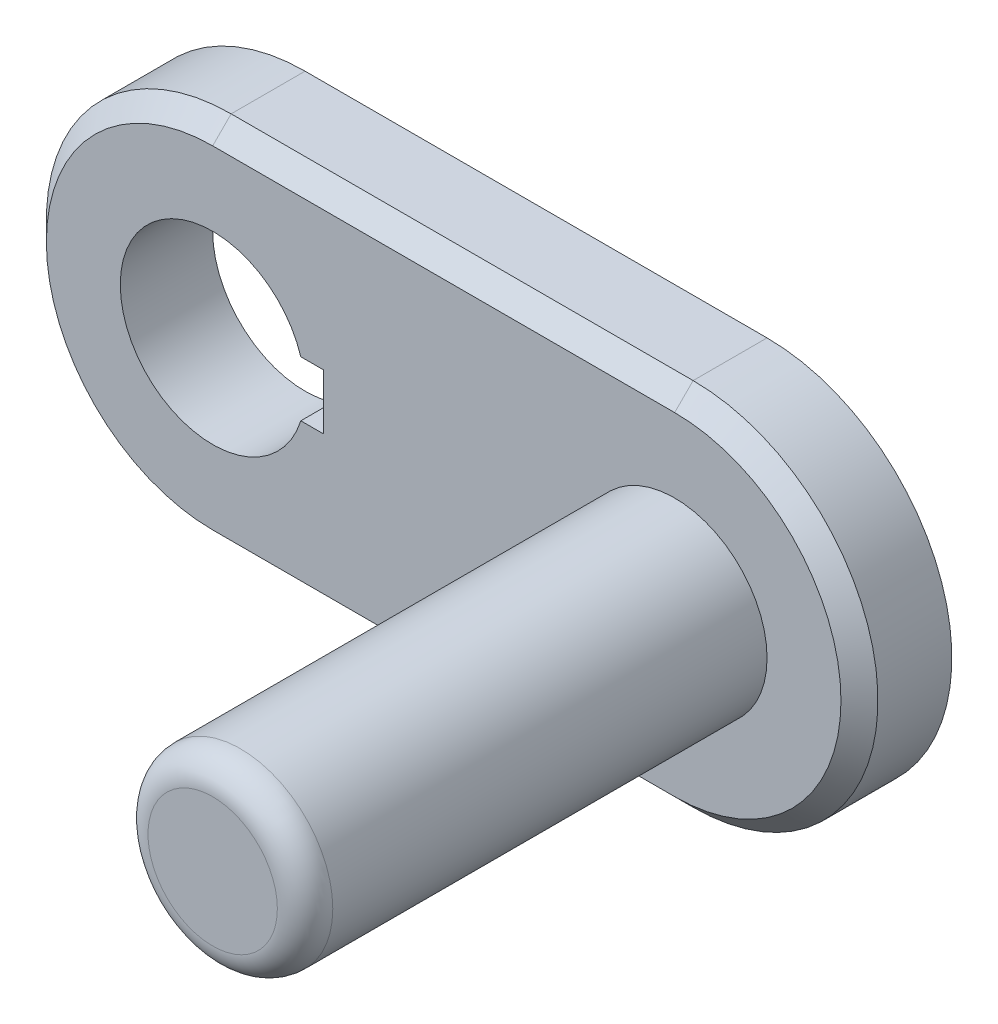
from build123d import *

# Parameters (mm, degrees)
BOSS_EXTRUDE1_DEPTH = 10
SKETCH2_R           = 10
BOSS_EXTRUDE2_DEPTH = 50
FILLET1_R           = 3
CHAMFER1_SIZE       = 2


with BuildPart() as part:
    # Sketch1 → Boss-Extrude1 (new body)
    with BuildSketch(Plane.XY):
        with BuildLine():
            Line((0, 20), (50, 20))
            ThreePointArc((50, 20), (70, 0), (50, -20))
            Line((50, -20), (0, -20))
            ThreePointArc((0, -20), (-20, 0), (0, 20))
        make_face()
        with BuildLine():
            Line((9.539392014, 3), (12, 3))
            Line((12, 3), (12, -3))
            Line((12, -3), (9.539392014, -3))
            ThreePointArc((9.539392014, -3), (-10, 0), (9.539392014, 3))
        make_face(mode=Mode.SUBTRACT)
    extrude(amount=BOSS_EXTRUDE1_DEPTH)

    # Sketch2 → Boss-Extrude2 (add)
    with BuildSketch(Plane.XY.offset(10)):
        with Locations((50, 0)):
            Circle(SKETCH2_R)
    extrude(amount=BOSS_EXTRUDE2_DEPTH)

    # Fillet1
    fillet1_edges = [part.edges().sort_by_distance(p)[0] for p in [
        (40, 0, 60),
    ]]
    fillet(fillet1_edges, radius=FILLET1_R)

    # Chamfer1
    chamfer1_edges = [part.edges().sort_by_distance(p)[0] for p in [
        (70, 0, 10),
        (25, 20, 10),
        (-20, 0, 10),
        (25, -20, 10),
    ]]
    chamfer(chamfer1_edges, length=CHAMFER1_SIZE)


solid = part.part
